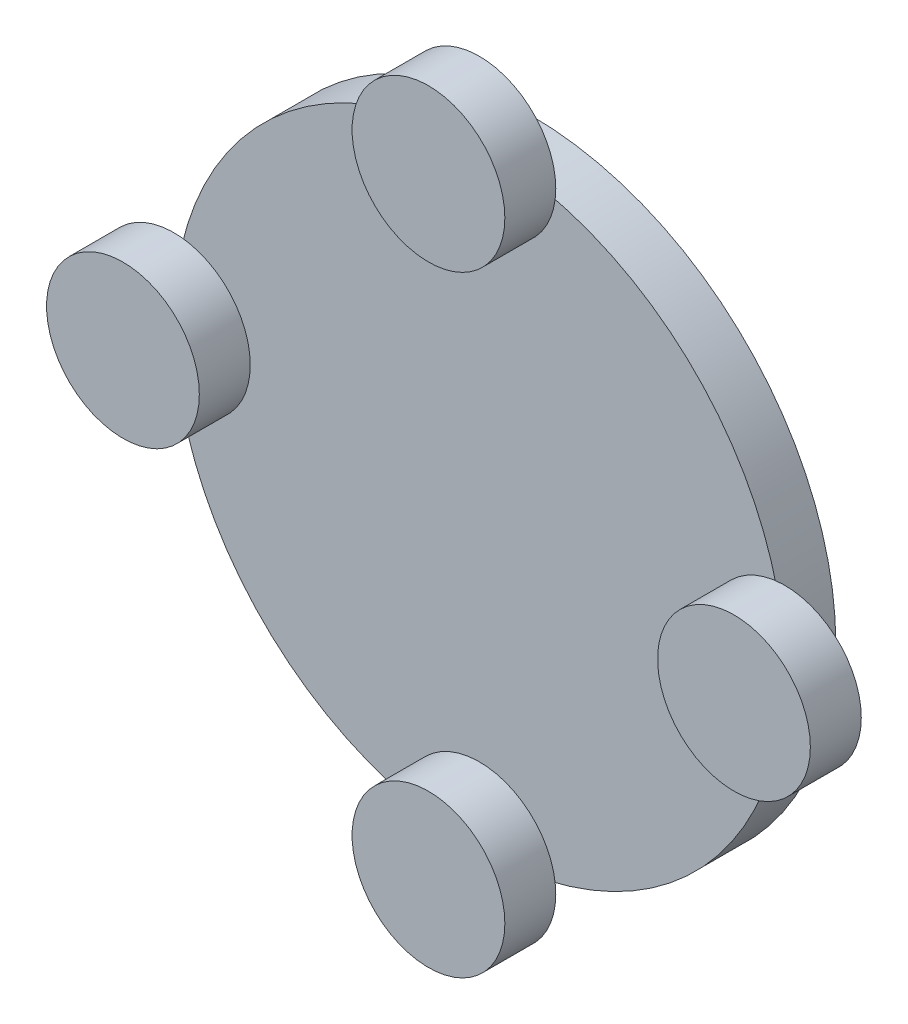
from build123d import *

# Parameters (mm, degrees)
SKIZZE1_R                 = 30
LINEAR_AUSTRAGEN1_DEPTH   = 5
SKIZZE1_3_R               = 7.5
LINEAR_AUSTRAGEN2_DEPTH   = 5
LINEAR_AUSTRAGEN2_2_DEPTH = 5
LINEAR_AUSTRAGEN2_3_DEPTH = 5
LINEAR_AUSTRAGEN2_4_DEPTH = 5


with BuildPart() as part:
    # Skizze1 → Linear austragen1 (new body)
    with BuildSketch(Plane.XY):
        Circle(SKIZZE1_R)
    extrude(amount=-LINEAR_AUSTRAGEN1_DEPTH)


with BuildPart() as body_2:
    # Skizze1_3 → Linear austragen2 (new body)
    with BuildSketch(Plane.XY):
        with Locations((0, 30)):
            Circle(SKIZZE1_3_R)
    extrude(amount=LINEAR_AUSTRAGEN2_DEPTH)


with BuildPart() as body_3:
    # Skizze1_3 → Linear austragen2 2 (new body)
    with BuildSketch(Plane.XY):
        with Locations((30, 0)):
            Circle(SKIZZE1_3_R)
    extrude(amount=LINEAR_AUSTRAGEN2_2_DEPTH)


with BuildPart() as body_4:
    # Skizze1_3 → Linear austragen2 3 (new body)
    with BuildSketch(Plane.XY):
        with Locations((0, -30)):
            Circle(SKIZZE1_3_R)
    extrude(amount=LINEAR_AUSTRAGEN2_3_DEPTH)


with BuildPart() as body_5:
    # Skizze1_3 → Linear austragen2 4 (new body)
    with BuildSketch(Plane.XY):
        with Locations((-30, 0)):
            Circle(SKIZZE1_3_R)
    extrude(amount=LINEAR_AUSTRAGEN2_4_DEPTH)


solid = Compound([part.part, body_2.part, body_3.part, body_4.part, body_5.part])
